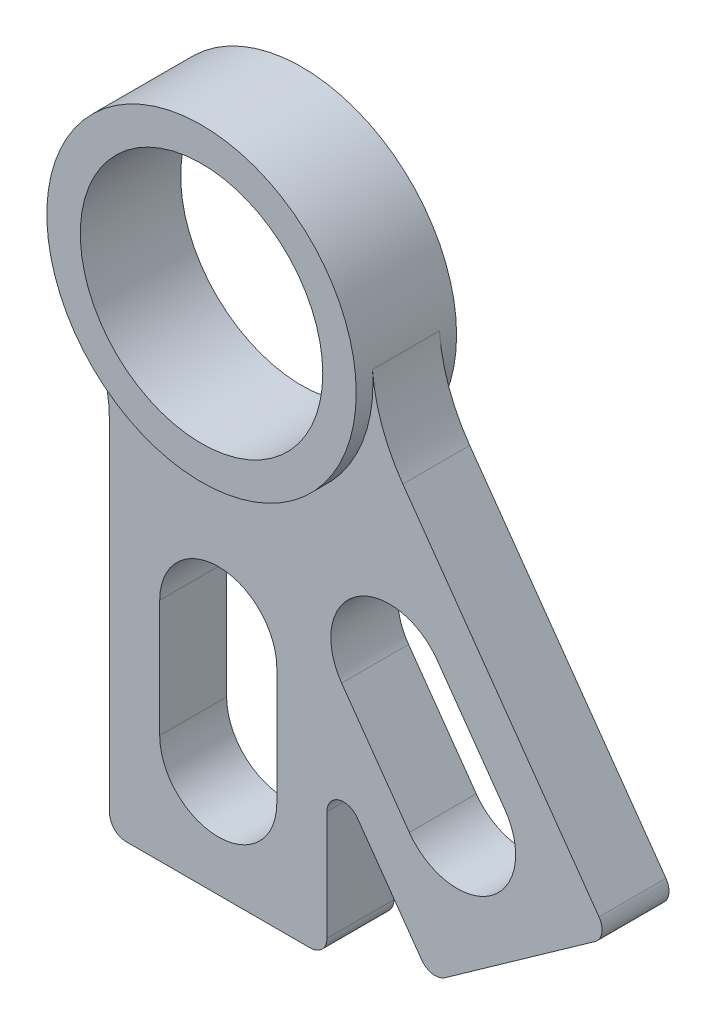
from build123d import *

# Parameters (mm, degrees)
SKETCH1_R                = 11.5062
BOSS_EXTRUDE1_DEPTH      = 4.7625
BOSS_EXTRUDE1_DEPTH_BACK = 4.7625
CUT_EXTRUDE1_START       = -4.7625
CUT_EXTRUDE1_DEPTH       = 1.5875
CUT_EXTRUDE2_START       = 3.175
CUT_EXTRUDE2_DEPTH       = 1.5875
FILLET1_R                = 1.5875


with BuildPart() as part:
    # Sketch1 → Boss-Extrude1 (new body, two sides)
    with BuildSketch(Plane.XY) as boss_extrude1_sk:
        with BuildLine():
            ThreePointArc((14.639156809, 1.110279863), (-4.45502565, 13.988937769), (-12.585193267, -7.559797873))
            ThreePointArc((-12.585193267, -7.559797873), (4.45502565, -13.988937769), (14.639156809, 1.110279863))
        make_face()
        Circle(SKETCH1_R, mode=Mode.SUBTRACT)
        with BuildLine():
            ThreePointArc((-12.585193267, -7.559797873), (4.45502565, -13.988937769), (14.639156809, 1.110279863))
            ThreePointArc((14.639156809, 1.110279863), (15.535368252, -3.075379389), (17.517315641, -6.869430374))
            Line((17.517315641, -6.869430374), (37.052935248, -34.429965394))
            Line((37.052935248, -34.429965394), (20.216142238, -46.364319477))
            Line((20.216142238, -46.364319477), (10.31875, -32.401239172))
            Line((10.31875, -32.401239172), (10.31875, -49.389319794))
            Line((10.31875, -49.389319794), (-10.31875, -49.389319794))
            Line((-10.31875, -49.389319794), (-10.31875, -15.734319794))
            ThreePointArc((-10.31875, -15.734319794), (-10.89585042, -11.492870345), (-12.585193267, -7.559797873))
        make_face()
        with BuildLine():
            ThreePointArc((20.774153775, -19.699685133), (13.028075711, -18.379797729), (11.708188308, -26.125875793))
            Line((11.708188308, -26.125875793), (18.134378968, -35.19184126))
            ThreePointArc((18.134378968, -35.19184126), (25.880457031, -36.511728663), (27.200344435, -28.7656506))
            Line((27.200344435, -28.7656506), (20.774153775, -19.699685133))
        make_face(mode=Mode.SUBTRACT)
        with BuildLine():
            ThreePointArc((5.55625, -27.958069794), (0, -22.401819794), (-5.55625, -27.958069794))
            Line((-5.55625, -27.958069794), (-5.55625, -39.070569794))
            ThreePointArc((-5.55625, -39.070569794), (0, -44.626819794), (5.55625, -39.070569794))
            Line((5.55625, -39.070569794), (5.55625, -27.958069794))
        make_face(mode=Mode.SUBTRACT)
    extrude(amount=BOSS_EXTRUDE1_DEPTH)
    extrude(boss_extrude1_sk.sketch, amount=-BOSS_EXTRUDE1_DEPTH_BACK)

    # Sketch2 → Cut-Extrude1 (cut)
    with BuildSketch(Plane.XY.offset(CUT_EXTRUDE1_START)):
        with BuildLine():
            Line((-10.31875, -15.734319794), (-10.31875, -49.389319794))
            Line((-10.31875, -49.389319794), (10.31875, -49.389319794))
            Line((10.31875, -49.389319794), (10.31875, -32.401239172))
            Line((10.31875, -32.401239172), (20.216142238, -46.364319477))
            Line((20.216142238, -46.364319477), (37.052935248, -34.429965394))
            Line((37.052935248, -34.429965394), (17.517315641, -6.869430374))
            ThreePointArc((17.517315641, -6.869430374), (15.535368252, -3.075379389), (14.639156809, 1.110279863))
            ThreePointArc((14.639156809, 1.110279863), (4.45502565, -13.988937769), (-12.585193267, -7.559797873))
            ThreePointArc((-12.585193267, -7.559797873), (-10.89585042, -11.492870345), (-10.31875, -15.734319794))
        make_face()
        with BuildLine():
            Line((-5.55625, -39.070569794), (-5.55625, -27.958069794))
            ThreePointArc((-5.55625, -27.958069794), (0, -22.401819794), (5.55625, -27.958069794))
            Line((5.55625, -27.958069794), (5.55625, -39.070569794))
            ThreePointArc((5.55625, -39.070569794), (0, -44.626819794), (-5.55625, -39.070569794))
        make_face(mode=Mode.SUBTRACT)
        with BuildLine():
            Line((18.134378968, -35.19184126), (11.708188308, -26.125875793))
            ThreePointArc((11.708188308, -26.125875793), (13.028075711, -18.379797729), (20.774153775, -19.699685133))
            Line((20.774153775, -19.699685133), (27.200344435, -28.7656506))
            ThreePointArc((27.200344435, -28.7656506), (25.880457031, -36.511728663), (18.134378968, -35.19184126))
        make_face(mode=Mode.SUBTRACT)
    extrude(amount=CUT_EXTRUDE1_DEPTH, mode=Mode.SUBTRACT)

    # Sketch2_6 → Cut-Extrude2 (cut)
    with BuildSketch(Plane.XY.offset(CUT_EXTRUDE2_START)):
        with BuildLine():
            Line((-10.31875, -15.734319794), (-10.31875, -49.389319794))
            Line((-10.31875, -49.389319794), (10.31875, -49.389319794))
            Line((10.31875, -49.389319794), (10.31875, -32.401239172))
            Line((10.31875, -32.401239172), (20.216142238, -46.364319477))
            Line((20.216142238, -46.364319477), (37.052935248, -34.429965394))
            Line((37.052935248, -34.429965394), (17.517315641, -6.869430374))
            ThreePointArc((17.517315641, -6.869430374), (15.535368252, -3.075379389), (14.639156809, 1.110279863))
            ThreePointArc((14.639156809, 1.110279863), (4.45502565, -13.988937769), (-12.585193267, -7.559797873))
            ThreePointArc((-12.585193267, -7.559797873), (-10.89585042, -11.492870345), (-10.31875, -15.734319794))
        make_face()
        with BuildLine():
            Line((-5.55625, -39.070569794), (-5.55625, -27.958069794))
            ThreePointArc((-5.55625, -27.958069794), (0, -22.401819794), (5.55625, -27.958069794))
            Line((5.55625, -27.958069794), (5.55625, -39.070569794))
            ThreePointArc((5.55625, -39.070569794), (0, -44.626819794), (-5.55625, -39.070569794))
        make_face(mode=Mode.SUBTRACT)
        with BuildLine():
            Line((18.134378968, -35.19184126), (11.708188308, -26.125875793))
            ThreePointArc((11.708188308, -26.125875793), (13.028075711, -18.379797729), (20.774153775, -19.699685133))
            Line((20.774153775, -19.699685133), (27.200344435, -28.7656506))
            ThreePointArc((27.200344435, -28.7656506), (25.880457031, -36.511728663), (18.134378968, -35.19184126))
        make_face(mode=Mode.SUBTRACT)
    extrude(amount=CUT_EXTRUDE2_DEPTH, mode=Mode.SUBTRACT)

    # Fillet1
    fillet1_edges = [part.edges().sort_by_distance(p)[0] for p in [
        (-10.31875, -49.389319794, 0),
        (10.31875, -49.389319794, 0),
        (10.31875, -32.401239172, 0),
        (20.216142238, -46.364319477, 0),
        (37.052935248, -34.429965394, 0),
    ]]
    fillet(fillet1_edges, radius=FILLET1_R)


solid = part.part
